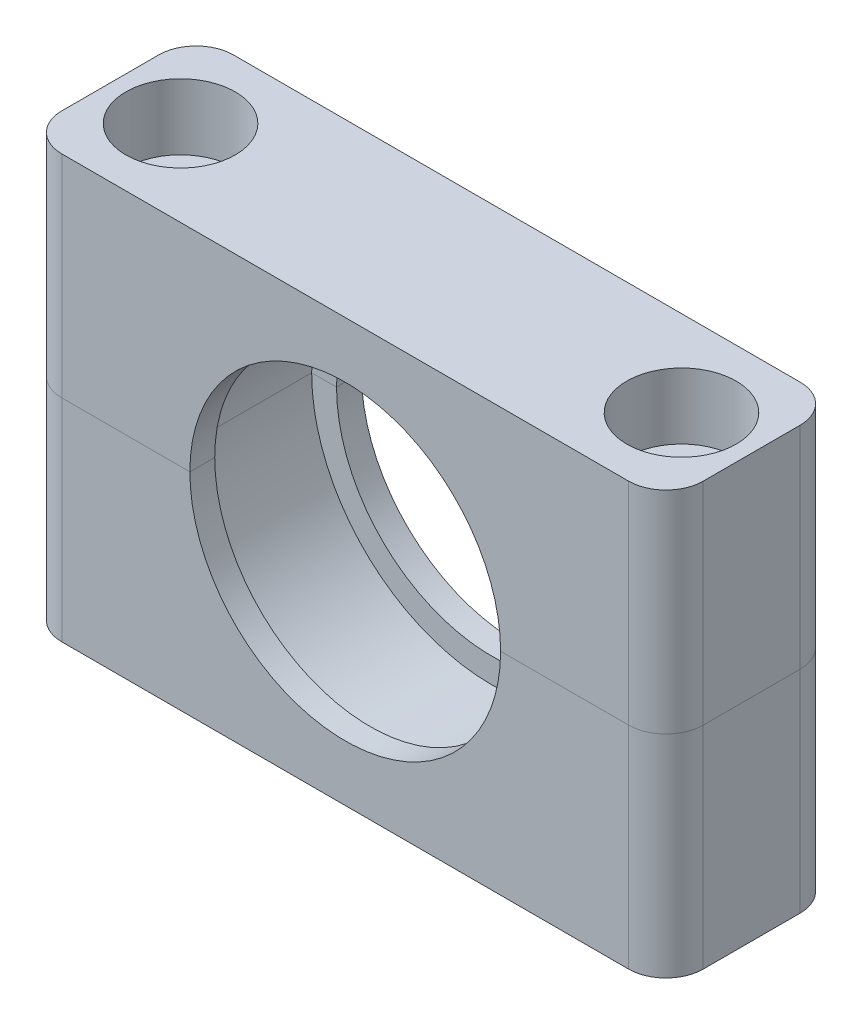
from build123d import *

# Parameters (mm, degrees)
SKETCH1_R               = 14.5
BOSS_EXTRUDE1_DEPTH     = 9.5
BOSS_EXTRUDE2_START     = 17
SKETCH2_W               = 51.6
SKETCH2_H               = 13.8
SKETCH2_R               = 2.65
BOSS_EXTRUDE2_DEPTH     = 34
SKETCH5_R               = 14.5
CUT_EXTRUDE2_DEPTH      = 1
CUT_EXTRUDE2_DEPTH_BACK = 14.8
SKETCH6_R               = 14.5
SKETCH6_R_2             = 12.5
BOSS_EXTRUDE4_DEPTH     = 2
SKETCH7_R               = 14.5
SKETCH7_R_2             = 12.5
BOSS_EXTRUDE5_DEPTH     = 2
SKETCH8_R               = 4.4
CUT_EXTRUDE3_DEPTH      = 1
CUT_EXTRUDE3_DEPTH_BACK = 5.3
FILLET1_R               = 3
FILLET2_R               = 3


with BuildPart() as part:
    # Sketch1 → Boss-Extrude1 (new body)
    with BuildSketch(Plane.XY):
        Circle(SKETCH1_R)
    extrude(amount=BOSS_EXTRUDE1_DEPTH)


with BuildPart() as body_2:
    # Sketch2 → Boss-Extrude2 (new body)
    with BuildSketch(Plane(origin=(0, 0, 0), x_dir=(1, 0, 0), z_dir=(0, 1, 0)).offset(BOSS_EXTRUDE2_START)):
        with Locations((0, -4.75)):
            Rectangle(SKETCH2_W, SKETCH2_H)
        with Locations((-20.15, -4.75)):
            Circle(SKETCH2_R, mode=Mode.SUBTRACT)
        with Locations((20.15, -4.75)):
            Circle(SKETCH2_R, mode=Mode.SUBTRACT)
    extrude(amount=-BOSS_EXTRUDE2_DEPTH)


with BuildPart() as cut_extrude2_tool:
    # Sketch5 → Cut-Extrude2 (new body, two sides)
    with BuildSketch(Plane.XY.offset(11.65)) as cut_extrude2_sk:
        Circle(SKETCH5_R)
    extrude(amount=CUT_EXTRUDE2_DEPTH)
    extrude(cut_extrude2_sk.sketch, amount=-CUT_EXTRUDE2_DEPTH_BACK)


with BuildPart() as part_1:
    add(part.part)

    # Cut-Extrude2: cut by cut_extrude2_tool
    add(cut_extrude2_tool.part, mode=Mode.SUBTRACT)


with BuildPart() as body_2_1:
    add(body_2.part)

    # Cut-Extrude2: cut by cut_extrude2_tool
    add(cut_extrude2_tool.part, mode=Mode.SUBTRACT)

    # Sketch6 → Boss-Extrude4 (add)
    with BuildSketch(Plane.XY.offset(11.65)):
        Circle(SKETCH6_R)
        Circle(SKETCH6_R_2, mode=Mode.SUBTRACT)
    extrude(amount=-BOSS_EXTRUDE4_DEPTH)

    # Sketch7 → Boss-Extrude5 (add)
    with BuildSketch(Plane(origin=(0, 0, -2.15), x_dir=(-1, 0, 0), z_dir=(0, 0, -1))):
        Circle(SKETCH7_R)
        Circle(SKETCH7_R_2, mode=Mode.SUBTRACT)
    extrude(amount=-BOSS_EXTRUDE5_DEPTH)


with BuildPart() as body_2_2:
    # Split1: the piece on the far side of the plane
    add(body_2_1.part)
    split(bisect_by=Plane.ZX, keep=Keep.BOTTOM)

    # Fillet2
    fillet2_edges = [body_2_2.edges().sort_by_distance(p)[0] for p in [
        (-25.8, -8.5, 11.65),
        (25.8, -8.5, 11.65),
        (25.8, -8.5, -2.15),
        (-25.8, -8.5, -2.15),
    ]]
    fillet(fillet2_edges, radius=FILLET2_R)


with BuildPart() as body_2_3:
    add(body_2_1.part)

    # Split1
    split(bisect_by=Plane.ZX, keep=Keep.TOP)

    # Sketch8 → Cut-Extrude3 (cut, two sides)
    with BuildSketch(Plane(origin=(0, 17, 0), x_dir=(1, 0, 0), z_dir=(0, 1, 0))) as cut_extrude3_sk:
        with Locations((-20.15, -4.75)):
            Circle(SKETCH8_R)
        with Locations((20.15, -4.75)):
            Circle(SKETCH8_R)
    extrude(amount=CUT_EXTRUDE3_DEPTH, mode=Mode.SUBTRACT)
    extrude(cut_extrude3_sk.sketch, amount=-CUT_EXTRUDE3_DEPTH_BACK, mode=Mode.SUBTRACT)

    # Fillet1
    fillet1_edges = [body_2_3.edges().sort_by_distance(p)[0] for p in [
        (-25.8, 8.5, 11.65),
        (25.8, 8.5, 11.65),
        (25.8, 8.5, -2.15),
        (-25.8, 8.5, -2.15),
    ]]
    fillet(fillet1_edges, radius=FILLET1_R)


solid = Compound([body_2_2.part, body_2_3.part])
